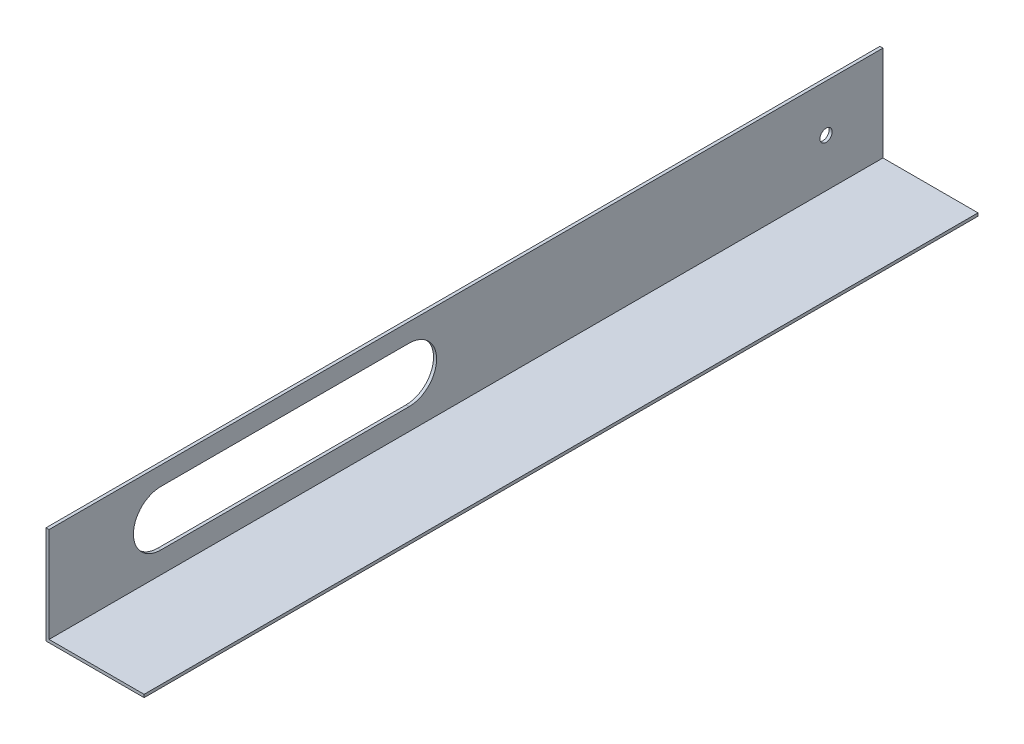
from build123d import *

# Parameters (mm, degrees)
BOSS_EXTRUDE2_DEPTH = 431.8
SKETCH8_R           = 3.175
CUT_EXTRUDE6_DEPTH  = 2.54


with BuildPart() as part:
    # Sketch3 → Boss-Extrude2 (new body)
    with BuildSketch(Plane.XY):
        Polygon((49.2125, 1.5875), (49.2125, 50.8), (50.8, 50.8), (50.8, 1.524), (100.0125, 1.524), (100.0125, 0), (49.2125, 0), align=None)
    extrude(amount=BOSS_EXTRUDE2_DEPTH)

    # Sketch8 → Cut-Extrude6 (cut)
    with BuildSketch(Plane(origin=(50.8, 0, 0), x_dir=(0, 0, -1), z_dir=(1, 0, 0))):
        with Locations((-29.464, 26.416)):
            Circle(SKETCH8_R)
        with BuildLine():
            Line((-245.364, 12.7), (-373.888, 12.7))
            ThreePointArc((-373.888, 12.7), (-388.112, 26.924), (-373.888, 41.148))
            Line((-373.888, 41.148), (-245.364, 41.148))
            ThreePointArc((-245.364, 41.148), (-231.14, 26.924), (-245.364, 12.7))
        make_face()
    extrude(amount=-CUT_EXTRUDE6_DEPTH, mode=Mode.SUBTRACT)


solid = part.part
